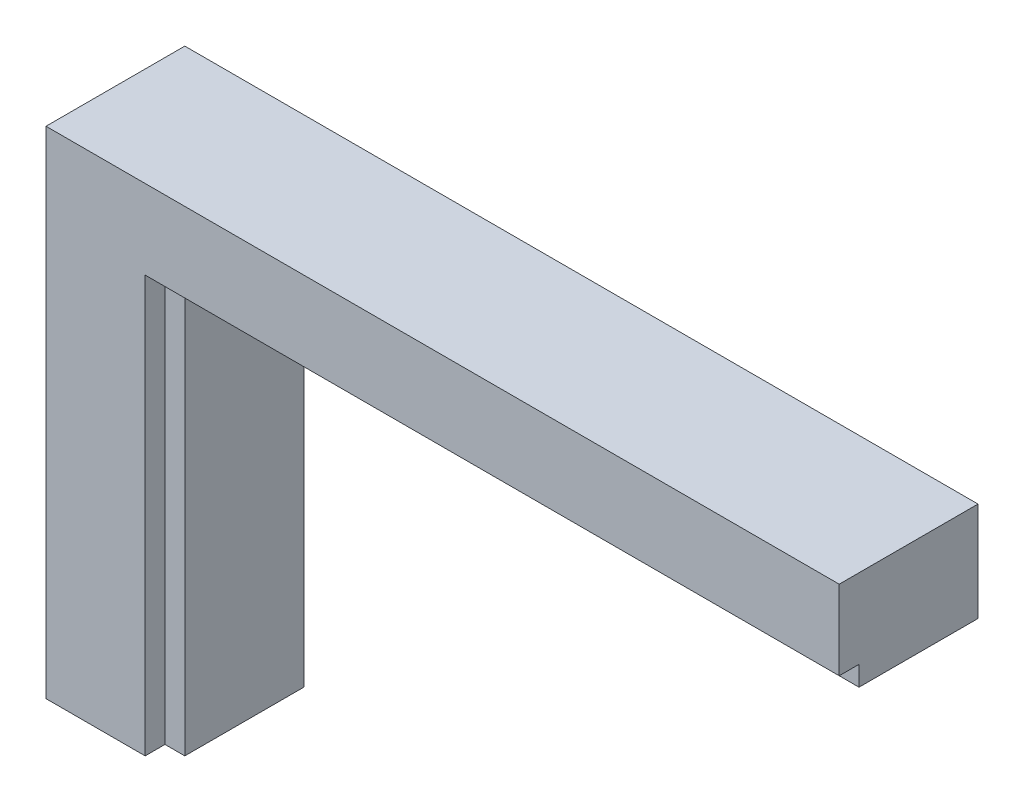
from build123d import *

# Parameters (mm, degrees)
EXTRUDE_1_DEPTH     = 70
SKETCH_3_W          = 10
SKETCH_3_H          = 10
CUT_EXTRUDE_1_DEPTH = 210
SKETCH_4_W          = 10
SKETCH_4_H          = 10
CUT_EXTRUDE_2_DEPTH = 340


with BuildPart() as part:
    # Эскиз2 → Бобышка-Вытянуть1 (new body)
    with BuildSketch(Plane.XY):
        Polygon((0, 0), (0, 250), (400, 250), (400, 200), (60, 200), (60, 0), align=None)
    extrude(amount=EXTRUDE_1_DEPTH)

    # Эскиз3 → Вырез-Вытянуть1 (cut)
    with BuildSketch(Plane.XZ):
        with Locations((55, 65)):
            Rectangle(SKETCH_3_W, SKETCH_3_H)
    extrude(amount=-CUT_EXTRUDE_1_DEPTH, mode=Mode.SUBTRACT)

    # Эскиз4 → Вырез-Вытянуть2 (cut)
    with BuildSketch(Plane(origin=(400, 0, 0), x_dir=(0, 0, -1), z_dir=(1, 0, 0))):
        with Locations((-65, 205)):
            Rectangle(SKETCH_4_W, SKETCH_4_H)
    extrude(amount=-CUT_EXTRUDE_2_DEPTH, mode=Mode.SUBTRACT)


solid = part.part
